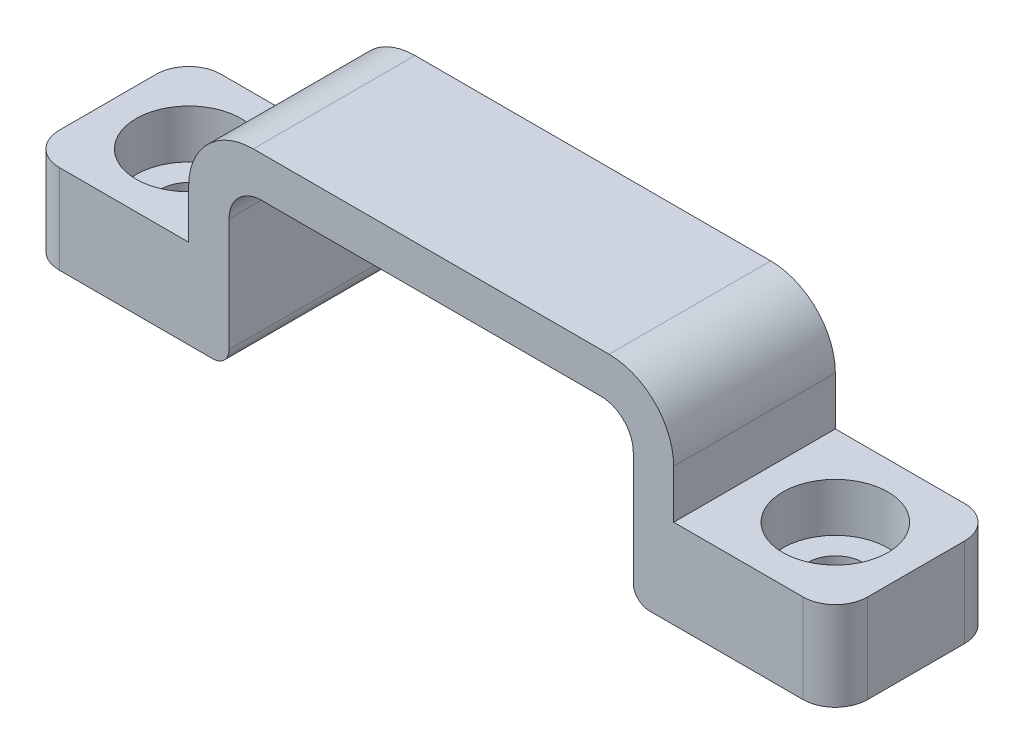
from build123d import *

# Parameters (mm, degrees)
BOSS_EXTRUDE1_DEPTH            = 5
FILLET1_R                      = 2
FILLET2_R                      = 4
FILLET3_R                      = 2
FILLET4_R                      = 1
CBORE_FOR_M3_SHCS2_D           = 3.4
CBORE_FOR_M3_SHCS2_CBORE_D     = 6.5
CBORE_FOR_M3_SHCS2_CBORE_DEPTH = 3


with BuildPart() as part:
    # Sketch1 → Boss-Extrude1 (new body, symmetric)
    with BuildSketch(Plane.XY):
        Polygon((-15, 2.5), (15, 2.5), (15, -4.5), (25, -4.5), (25, -10), (15, -10), (12.5, -10), (12.5, 0), (-12.5, 0), (-12.5, -10), (-15, -10), (-25, -10), (-25, -4.5), (-15, -4.5), align=None)
    extrude(amount=BOSS_EXTRUDE1_DEPTH, both=True)

    # Fillet1
    fillet1_edges = [part.edges().sort_by_distance(p)[0] for p in [
        (12.5, 0, 0),
        (-12.5, 0, 0),
    ]]
    fillet(fillet1_edges, radius=FILLET1_R)

    # Fillet2
    fillet2_edges = [part.edges().sort_by_distance(p)[0] for p in [
        (-15, 2.5, 0),
        (15, 2.5, 0),
    ]]
    fillet(fillet2_edges, radius=FILLET2_R)

    # Fillet3
    fillet3_edges = [part.edges().sort_by_distance(p)[0] for p in [
        (25, -7.25, -5),
        (-25, -7.25, -5),
        (-25, -7.25, 5),
        (25, -7.25, 5),
    ]]
    fillet(fillet3_edges, radius=FILLET3_R)

    # Fillet4
    fillet4_edges = [part.edges().sort_by_distance(p)[0] for p in [
        (12.5, -10, 0),
        (-12.5, -10, 0),
    ]]
    fillet(fillet4_edges, radius=FILLET4_R)

    # CBORE for M3 SHCS2 (through all)
    with Locations(Plane(origin=(0, -4.5, 0), x_dir=(1, 0, 0), z_dir=(0, 1, 0))):
        with Locations((20, 0), (-20, 0)):
            CounterBoreHole(CBORE_FOR_M3_SHCS2_D / 2, CBORE_FOR_M3_SHCS2_CBORE_D / 2, CBORE_FOR_M3_SHCS2_CBORE_DEPTH)


solid = part.part
